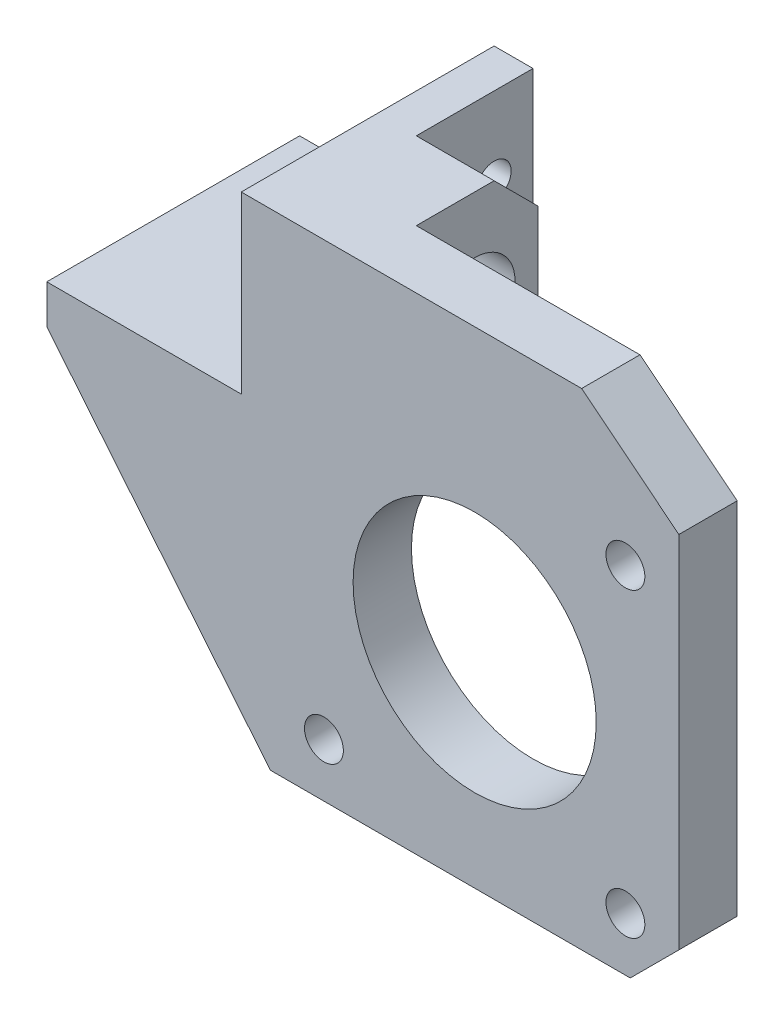
from build123d import *

# Parameters (mm, degrees)
ESBO_O1_R                = 12.5
ESBO_O1_R_2              = 2
RESSALTO_EXTRUS_O1_DEPTH = 6
RESSALTO_EXTRUS_O2_DEPTH = 20
ESBO_O3_R                = 4.15
RESSALTO_EXTRUS_O3_DEPTH = 8
ESBO_O5_R                = 1.75
ESBO_O5_R_2              = 4.15
CORTE_EXTRUS_O2_DEPTH    = 12
ESBO_O6_R                = 1.75
CORTE_EXTRUS_O3_DEPTH    = 12
CHANFRO1_SIZE            = 5
ESBO_O8_R                = 5.25
CORTE_EXTRUS_O5_DEPTH    = 1
ESBO_O9_R                = 5.25
CORTE_EXTRUS_O6_DEPTH    = 1


with BuildPart() as part:
    # Esboço1 → Ressalto-extrusão1 (new body)
    with BuildSketch(Plane.XY):
        Polygon((-44, 7), (-21, -21), (21, -21), (21, 21), (11, 29), (-24, 29), (-24, 21), (-24, 11), (-44, 11), align=None)
        Circle(ESBO_O1_R, mode=Mode.SUBTRACT)
        with Locations((15.5, 15.5)):
            Circle(ESBO_O1_R_2, mode=Mode.SUBTRACT)
        with Locations((15.5, -15.5)):
            Circle(ESBO_O1_R_2, mode=Mode.SUBTRACT)
        with Locations((-15.5, -15.5)):
            Circle(ESBO_O1_R_2, mode=Mode.SUBTRACT)
    extrude(amount=RESSALTO_EXTRUS_O1_DEPTH)

    # Esboço2 → Ressalto-extrusão2 (add)
    with BuildSketch(Plane(origin=(0, 0, 0), x_dir=(-1, 0, 0), z_dir=(0, 0, -1))):
        with BuildLine():
            Line((44, 11), (44, 7))
            Line((44, 7), (24, 7))
            ThreePointArc((24, 7), (21.171572875, 8.171572875), (20, 11))
            Line((20, 11), (20, 29))
            Line((20, 29), (24, 29))
            Line((24, 29), (24, 11))
            Line((24, 11), (44, 11))
        make_face()
    extrude(amount=RESSALTO_EXTRUS_O2_DEPTH)

    # Esboço3 → Ressalto-extrusão3 (add)
    with BuildSketch(Plane(origin=(-20, 0, 0), x_dir=(0, 0, -1), z_dir=(1, 0, 0))):
        Polygon((0, 29), (8, 29), (12.5, 24.5), (12.5, 13.5), (8, 9), (0, 9), align=None)
        with Locations((6, 19)):
            Circle(ESBO_O3_R, mode=Mode.SUBTRACT)
    extrude(amount=RESSALTO_EXTRUS_O3_DEPTH)

    # Esboço5 → Corte-extrusão2 (cut)
    with BuildSketch(Plane(origin=(-20, 0, 0), x_dir=(0, 0, -1), z_dir=(1, 0, 0))):
        with Locations((16, 21)):
            Circle(ESBO_O5_R)
        with Locations((6, 19)):
            Circle(ESBO_O5_R_2)
    extrude(amount=-CORTE_EXTRUS_O2_DEPTH, mode=Mode.SUBTRACT)

    # Esboço6 → Corte-extrusão3 (cut)
    with BuildSketch(Plane(origin=(0, 7, 0), x_dir=(-1, 0, 0), z_dir=(0, -1, 0))):
        with Locations((34.5, 13)):
            Circle(ESBO_O6_R)
    extrude(amount=-CORTE_EXTRUS_O3_DEPTH, mode=Mode.SUBTRACT)

    # Chanfro1
    chanfro1_edges = [part.edges().sort_by_distance(p)[0] for p in [
        (21, -21, 3),
    ]]
    chamfer(chanfro1_edges, length=CHANFRO1_SIZE)

    # Esboço8 → Corte-extrusão5 (cut)
    with BuildSketch(Plane.ZY.offset(24)):
        with Locations((-16, 21)):
            Circle(ESBO_O8_R)
    extrude(amount=-CORTE_EXTRUS_O5_DEPTH, mode=Mode.SUBTRACT)

    # Esboço9 → Corte-extrusão6 (cut)
    with BuildSketch(Plane(origin=(0, 11, 0), x_dir=(1, 0, 0), z_dir=(0, 1, 0))):
        with Locations((-34.5, 13)):
            Circle(ESBO_O9_R)
    extrude(amount=-CORTE_EXTRUS_O6_DEPTH, mode=Mode.SUBTRACT)


solid = part.part
